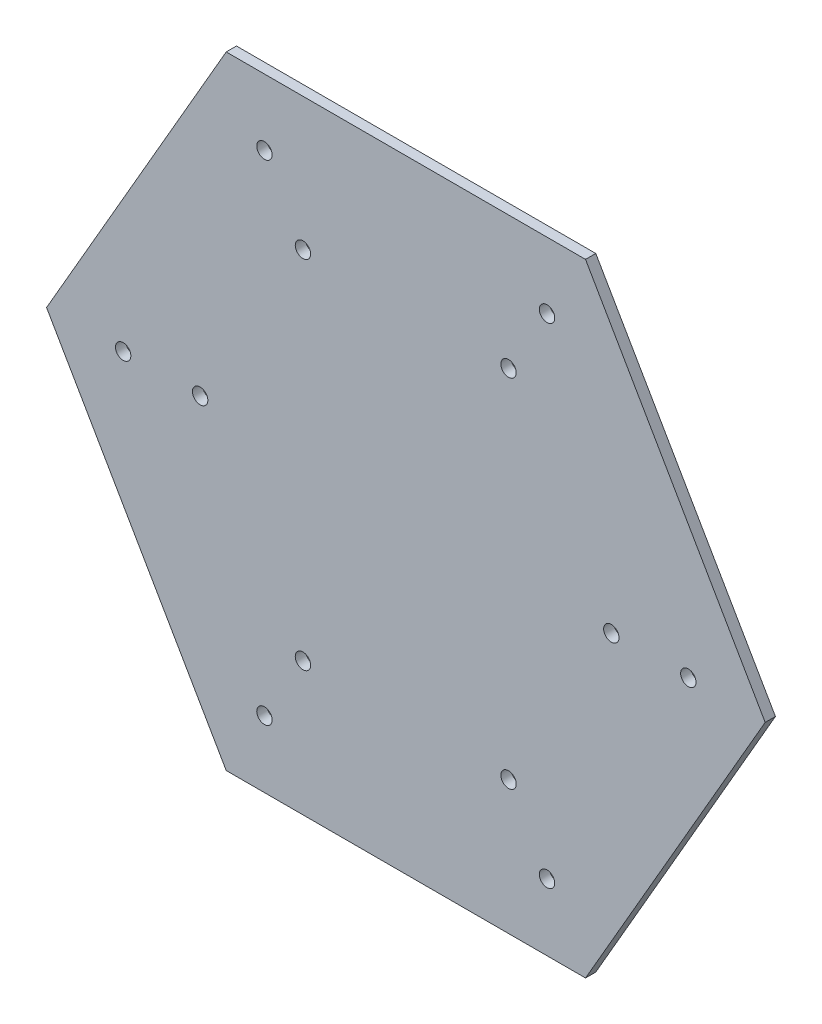
from build123d import *

# Parameters (mm, degrees)
BOSS_EXTRUDE1_DEPTH = 2
SKETCH3_R           = 1.5
CUT_EXTRUDE1_DEPTH  = 2
CIRPATTERN1_COUNT   = 6


with BuildPart() as part:
    # Sketch2 → Boss-Extrude1 (new body)
    with BuildSketch(Plane.XY):
        Polygon((35, -60.621778265), (70, 0), (35, 60.621778265), (-35, 60.621778265), (-70, 0), (-35, -60.621778265), align=None)
    extrude(amount=BOSS_EXTRUDE1_DEPTH)

    # Sketch3 → Cut-Extrude1 (cut)
    with BuildSketch(Plane.XY):
        with Locations((27.5, -47.631397208)):
            Circle(SKETCH3_R)
        with Locations((20, -34.641016151)):
            Circle(SKETCH3_R)
    cut_extrude1 = extrude(amount=CUT_EXTRUDE1_DEPTH, mode=Mode.SUBTRACT)

    # CirPattern1: Cut-Extrude1 ×6 about axis
    cirpattern1_axis = Axis((-0.026403444, 0.045732107, 0), (0, 0, 1))
    for i in range(1, CIRPATTERN1_COUNT):
        add(cut_extrude1.rotate(cirpattern1_axis, i * 360 / CIRPATTERN1_COUNT), mode=Mode.SUBTRACT)


solid = part.part
